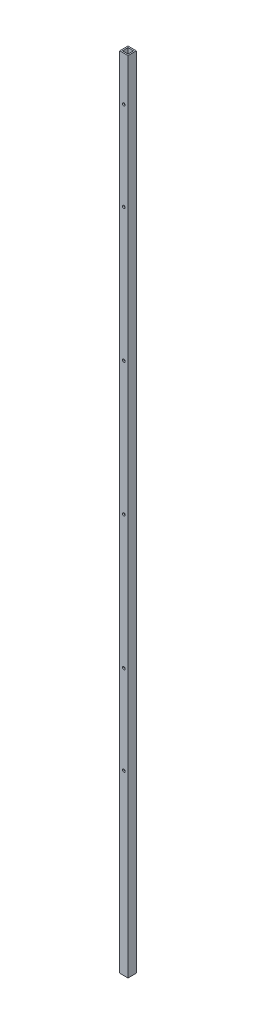
from build123d import *

# Parameters (mm, degrees)
SKETCH1_W           = 19.05
SKETCH1_H           = 19.05
BOSS_EXTRUDE1_DEPTH = 1828.8
SKETCH2_W           = 12.7
SKETCH2_H           = 12.7
CUT_EXTRUDE1_DEPTH  = 1829.8
SKETCH3_R           = 3.175
CUT_EXTRUDE2_DEPTH  = 20.05


with BuildPart() as part:
    # Sketch1 → Boss-Extrude1 (new body)
    with BuildSketch(Plane(origin=(0, 0, 0), x_dir=(1, 0, 0), z_dir=(0, 1, 0))):
        with Locations((9.525, 9.525)):
            Rectangle(SKETCH1_W, SKETCH1_H)
    extrude(amount=BOSS_EXTRUDE1_DEPTH)

    # Sketch2 → Cut-Extrude1 (cut, through all)
    with BuildSketch(Plane(origin=(0, 1828.8, 0), x_dir=(1, 0, 0), z_dir=(0, 1, 0))):
        with Locations((9.525, 9.525)):
            Rectangle(SKETCH2_W, SKETCH2_H)
    extrude(amount=-CUT_EXTRUDE1_DEPTH, mode=Mode.SUBTRACT)

    # Sketch3 → Cut-Extrude2 (cut, through all)
    with BuildSketch(Plane.XY):
        with Locations((9.525, 1727.2)):
            Circle(SKETCH3_R)
        with Locations((9.525, 1524)):
            Circle(SKETCH3_R)
        with Locations((9.525, 1219.2)):
            Circle(SKETCH3_R)
        with Locations((9.525, 914.4)):
            Circle(SKETCH3_R)
        with Locations((9.525, 406.4)):
            Circle(SKETCH3_R)
        with Locations((9.525, 609.6)):
            Circle(SKETCH3_R)
    extrude(amount=-CUT_EXTRUDE2_DEPTH, mode=Mode.SUBTRACT)


solid = part.part
